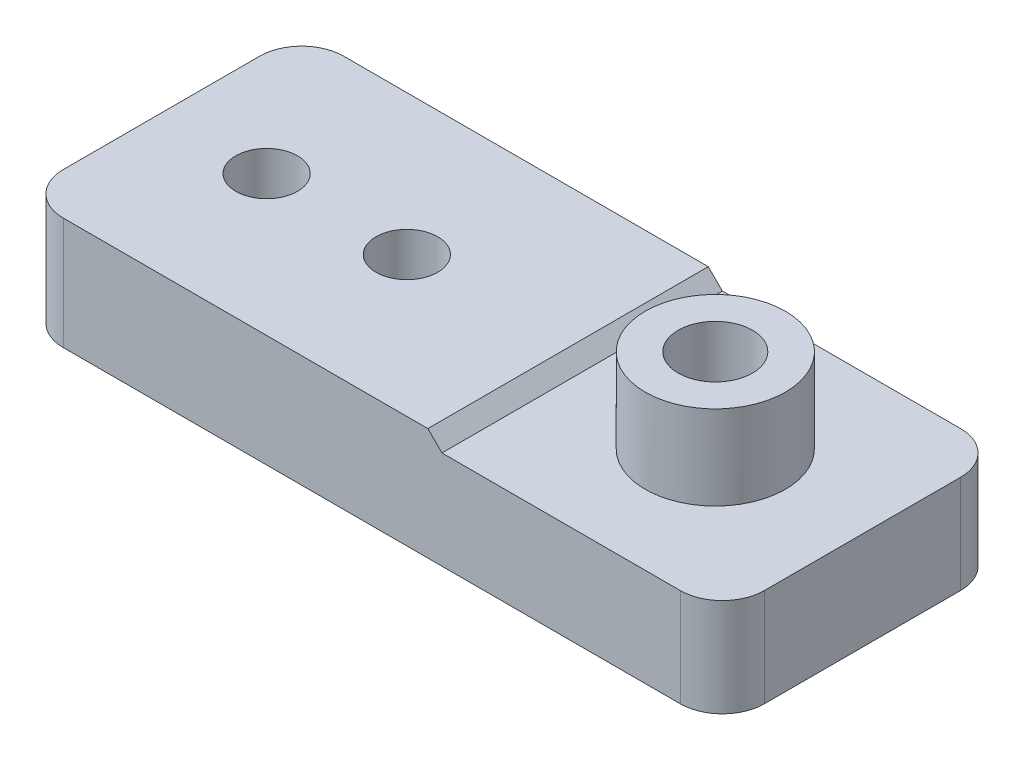
from build123d import *

# Parameters (mm, degrees)
CROQUIS1_R              = 2.2
CROQUIS1_R_2            = 5
SALIENTE_EXTRUIR1_DEPTH = 8
CORTAR_EXTRUIR1_DEPTH   = 26
CROQUIS1_3_R            = 5
CROQUIS1_3_R_2          = 2.65
SALIENTE_EXTRUIR2_DEPTH = 13


with BuildPart() as part:
    # Croquis1 → Saliente-Extruir1 (new body)
    with BuildSketch(Plane(origin=(0, 0, 0), x_dir=(1, 0, 0), z_dir=(0, 1, 0))):
        with BuildLine():
            ThreePointArc((-25, -7), (-24.121320344, -9.121320344), (-22, -10))
            Line((-22, -10), (22, -10))
            ThreePointArc((22, -10), (24.121320344, -9.121320344), (25, -7))
            Line((25, -7), (25, 7))
            ThreePointArc((25, 7), (24.121320344, 9.121320344), (22, 10))
            Line((22, 10), (-22, 10))
            ThreePointArc((-22, 10), (-24.121320344, 9.121320344), (-25, 7))
            Line((-25, 7), (-25, -7))
        make_face()
        with Locations((-17.5, 0)):
            Circle(CROQUIS1_R, mode=Mode.SUBTRACT)
        with Locations((-7.5, 0)):
            Circle(CROQUIS1_R, mode=Mode.SUBTRACT)
        with Locations((14.5, 0)):
            Circle(CROQUIS1_R_2, mode=Mode.SUBTRACT)
    extrude(amount=SALIENTE_EXTRUIR1_DEPTH)

    # Croquis2 → Cortar-Extruir1 (cut)
    with BuildSketch(Plane.XY.offset(10)):
        Polygon((4, 8), (5.004091629, 6.995908371), (27.295002856, 6.995908371), (27.295002856, 8), align=None)
    extrude(amount=-CORTAR_EXTRUIR1_DEPTH, mode=Mode.SUBTRACT)

    # Croquis1_3 → Saliente-Extruir2 (add)
    with BuildSketch(Plane(origin=(0, 0, 0), x_dir=(1, 0, 0), z_dir=(0, 1, 0))):
        with Locations((14.5, 0)):
            Circle(CROQUIS1_3_R)
        with Locations((14.5, 0)):
            Circle(CROQUIS1_3_R_2, mode=Mode.SUBTRACT)
    extrude(amount=SALIENTE_EXTRUIR2_DEPTH)


solid = part.part
